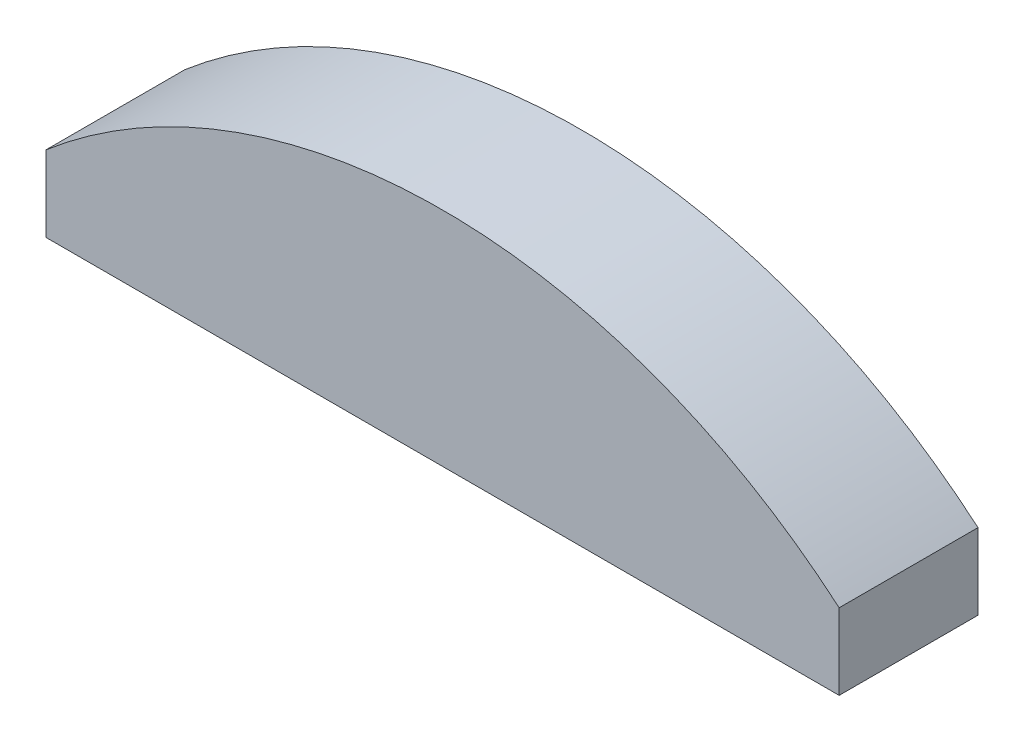
from build123d import *

# Parameters (mm, degrees)
SALIENTE_EXTRUIR1_DEPTH = 5


with BuildPart() as part:
    # Croquis2 → Saliente-Extruir1 (new body, symmetric)
    with BuildSketch(Plane.XY):
        with BuildLine():
            Line((28.565713714, 28), (28.565713714, 33.466397358))
            ThreePointArc((28.565713714, 33.466397358), (0, 43.999997184), (-28.565713714, 33.466397358))
            Line((-28.565713714, 33.466397358), (-28.565713714, 28))
            Line((-28.565713714, 28), (28.565713714, 28))
        make_face()
    extrude(amount=SALIENTE_EXTRUIR1_DEPTH, both=True)


solid = part.part
